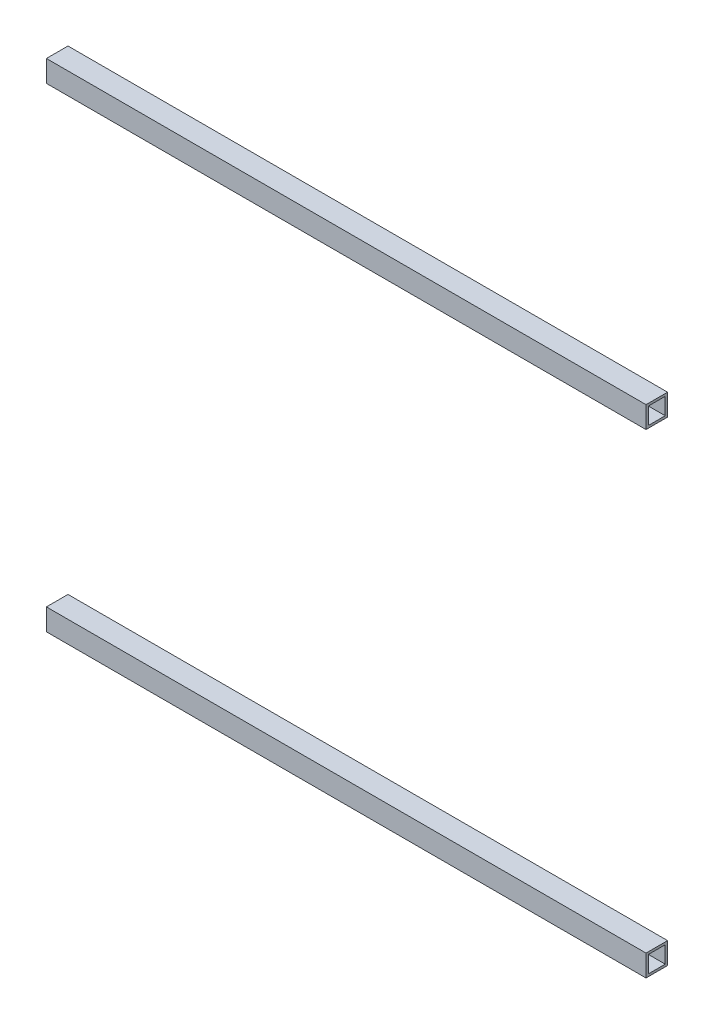
from build123d import *

# Parameters (mm, degrees)
SKETCH11_W                                    = 19.05
SKETCH11_H                                    = 19.05
SKETCH11_W_2                                  = 14.8336
SKETCH11_H_2                                  = 14.8336
AL_TUBE_SQUARE_AL_TUBE_0_75_SQR_X_0_083_DEPTH = 529.05
SKETCH11_ON_SEGMENT_2_W                       = 19.05
SKETCH11_ON_SEGMENT_2_H                       = 19.05
SKETCH11_ON_SEGMENT_2_W_2                     = 14.8336
SKETCH11_ON_SEGMENT_2_H_2                     = 14.8336
AL_TUBE_SQUARE_AL_TUBE_0_75_SQR_X_0_2_DEPTH   = 529.05


with BuildPart() as part:
    # Sketch11 → Al tube square AL TUBE 0.75 SQR X 0.083 WALL(1) (new body)
    with BuildSketch(Plane(origin=(0, 419.05, 0), x_dir=(0, 1, 0), z_dir=(1, 0, 0))):
        Rectangle(SKETCH11_W, SKETCH11_H)
        Rectangle(SKETCH11_W_2, SKETCH11_H_2, mode=Mode.SUBTRACT)
    extrude(amount=AL_TUBE_SQUARE_AL_TUBE_0_75_SQR_X_0_083_DEPTH)


with BuildPart() as body_2:
    # Sketch11 on segment 2 (carried to segment 2) → Al tube square AL TUBE 0.75 SQR X 0. 2 (new body)
    with BuildSketch(Plane.YZ):
        Rectangle(SKETCH11_ON_SEGMENT_2_W, SKETCH11_ON_SEGMENT_2_H)
        Rectangle(SKETCH11_ON_SEGMENT_2_W_2, SKETCH11_ON_SEGMENT_2_H_2, mode=Mode.SUBTRACT)
    extrude(amount=AL_TUBE_SQUARE_AL_TUBE_0_75_SQR_X_0_2_DEPTH)


solid = Compound([part.part, body_2.part])
